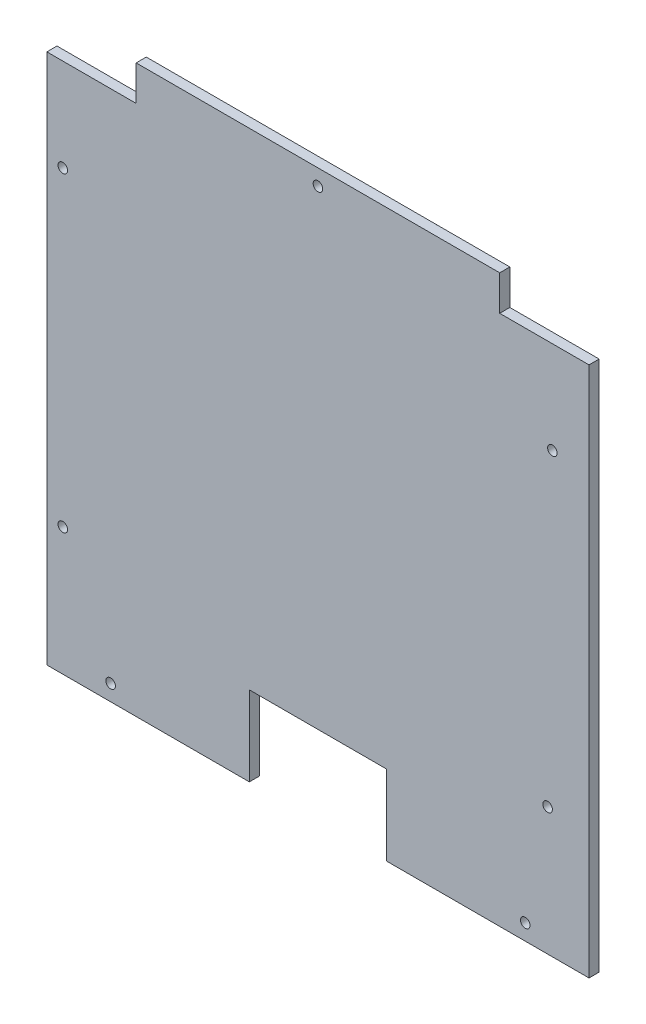
from build123d import *

# Parameters (mm, degrees)
SKETCH1_R           = 3
BOSS_EXTRUDE1_DEPTH = 6.35


with BuildPart() as part:
    # Sketch1 → Boss-Extrude1 (new body)
    with BuildSketch(Plane.XY):
        Polygon((0, 333), (0, 0), (127, 0), (127, 50), (213, 50), (213, 0), (340, 0), (340, 333), (284, 333), (284, 355), (56, 355), (56, 333), align=None)
        with Locations((40, 10)):
            Circle(SKETCH1_R, mode=Mode.SUBTRACT)
        with Locations((10, 80)):
            Circle(SKETCH1_R, mode=Mode.SUBTRACT)
        with Locations((300, 10)):
            Circle(SKETCH1_R, mode=Mode.SUBTRACT)
        with Locations((314.023307373, 80)):
            Circle(SKETCH1_R, mode=Mode.SUBTRACT)
        with Locations((10, 275)):
            Circle(SKETCH1_R, mode=Mode.SUBTRACT)
        with Locations((170, 345)):
            Circle(SKETCH1_R, mode=Mode.SUBTRACT)
        with Locations((317.023307373, 275)):
            Circle(SKETCH1_R, mode=Mode.SUBTRACT)
    extrude(amount=BOSS_EXTRUDE1_DEPTH)


solid = part.part
